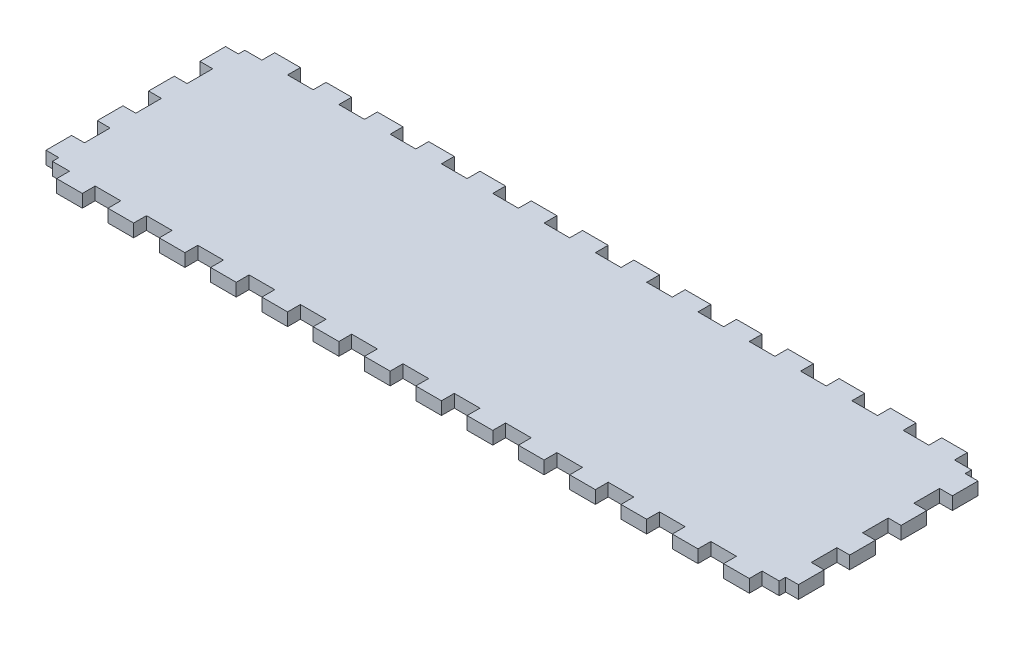
from build123d import *

# Parameters (mm, degrees)
SKETCH1_W                = 170
SKETCH1_H                = 45
BOSS_EXTRUDE1_DEPTH      = 3
SKETCH2_W                = 6
SKETCH2_H                = 3
BOSS_EXTRUDE2_DEPTH      = 3
LPATTERN1_COUNT          = 7
LPATTERN1_PITCH          = 12
LPATTERN1_COL_COUNT      = 8
LPATTERN1_COL_PITCH      = 12
SKETCH3_W                = 6
SKETCH3_H                = 3
BOSS_EXTRUDE3_DEPTH      = 3
LPATTERN2_COUNT          = 2
LPATTERN2_PITCH          = 12
LPATTERN2_COL_COUNT      = 3
LPATTERN2_COL_PITCH      = 12
MIRROR1_COPY_1_SKETCH_W  = 6
MIRROR1_COPY_1_SKETCH_H  = 3
MIRROR1_COPY_1_DEPTH     = 3
MIRROR1_COPY_2_SKETCH_W  = 6
MIRROR1_COPY_2_SKETCH_H  = 3
MIRROR1_COPY_2_DEPTH     = 3
MIRROR1_COPY_3_SKETCH_W  = 6
MIRROR1_COPY_3_SKETCH_H  = 3
MIRROR1_COPY_3_DEPTH     = 3
MIRROR1_COPY_4_SKETCH_W  = 6
MIRROR1_COPY_4_SKETCH_H  = 3
MIRROR1_COPY_4_DEPTH     = 3
MIRROR1_COPY_5_SKETCH_W  = 6
MIRROR1_COPY_5_SKETCH_H  = 3
MIRROR1_COPY_5_DEPTH     = 3
MIRROR1_COPY_6_SKETCH_W  = 6
MIRROR1_COPY_6_SKETCH_H  = 3
MIRROR1_COPY_6_DEPTH     = 3
MIRROR1_COPY_7_SKETCH_W  = 6
MIRROR1_COPY_7_SKETCH_H  = 3
MIRROR1_COPY_7_DEPTH     = 3
MIRROR1_COPY_8_SKETCH_W  = 6
MIRROR1_COPY_8_SKETCH_H  = 3
MIRROR1_COPY_8_DEPTH     = 3
MIRROR1_COPY_9_SKETCH_W  = 6
MIRROR1_COPY_9_SKETCH_H  = 3
MIRROR1_COPY_9_DEPTH     = 3
MIRROR1_COPY_10_SKETCH_W = 6
MIRROR1_COPY_10_SKETCH_H = 3
MIRROR1_COPY_10_DEPTH    = 3
MIRROR1_COPY_11_SKETCH_W = 6
MIRROR1_COPY_11_SKETCH_H = 3
MIRROR1_COPY_11_DEPTH    = 3
MIRROR1_COPY_12_SKETCH_W = 6
MIRROR1_COPY_12_SKETCH_H = 3
MIRROR1_COPY_12_DEPTH    = 3
MIRROR1_COPY_13_SKETCH_W = 6
MIRROR1_COPY_13_SKETCH_H = 3
MIRROR1_COPY_13_DEPTH    = 3
MIRROR2_COPY_1_SKETCH_W  = 6
MIRROR2_COPY_1_SKETCH_H  = 3
MIRROR2_COPY_1_DEPTH     = 3
MIRROR2_COPY_2_SKETCH_W  = 6
MIRROR2_COPY_2_SKETCH_H  = 3
MIRROR2_COPY_2_DEPTH     = 3
MIRROR2_COPY_3_SKETCH_W  = 6
MIRROR2_COPY_3_SKETCH_H  = 3
MIRROR2_COPY_3_DEPTH     = 3


with BuildPart() as part:
    # Sketch1 → Boss-Extrude1 (new body)
    with BuildSketch(Plane(origin=(0, 0, 0), x_dir=(1, 0, 0), z_dir=(0, 1, 0))):
        Rectangle(SKETCH1_W, SKETCH1_H)
    extrude(amount=BOSS_EXTRUDE1_DEPTH)

    # Sketch2 → Boss-Extrude2 (add)
    with BuildSketch(Plane.XY.offset(22.5)):
        with Locations((6, 1.5)):
            Rectangle(SKETCH2_W, SKETCH2_H)
    boss_extrude2 = extrude(amount=BOSS_EXTRUDE2_DEPTH)

    # LPattern1: Boss-Extrude2 ×7
    with Locations(*[(i * LPATTERN1_PITCH, 0, 0) for i in range(1, LPATTERN1_COUNT)]):
        add(boss_extrude2)

    # LPattern1 col: Boss-Extrude2 ×8
    with Locations(*[(-i * LPATTERN1_COL_PITCH, 0, 0) for i in range(1, LPATTERN1_COL_COUNT)]):
        add(boss_extrude2)

    # Sketch3 → Boss-Extrude3 (add)
    with BuildSketch(Plane(origin=(85, 0, 0), x_dir=(0, 0, -1), z_dir=(1, 0, 0))):
        with Locations((6, 1.5)):
            Rectangle(SKETCH3_W, SKETCH3_H)
    boss_extrude3 = extrude(amount=BOSS_EXTRUDE3_DEPTH)

    # LPattern2: Boss-Extrude3 ×2
    with Locations(*[(0, 0, -i * LPATTERN2_PITCH) for i in range(1, LPATTERN2_COUNT)]):
        add(boss_extrude3)

    # LPattern2 col: Boss-Extrude3 ×3
    with Locations(*[(0, 0, i * LPATTERN2_COL_PITCH) for i in range(1, LPATTERN2_COL_COUNT)]):
        add(boss_extrude3)

    # Mirror1: Boss-Extrude2 across plane
    add(boss_extrude2.mirror(Plane(origin=(0, 0, 0), x_dir=(1, 0, 0), z_dir=(0, 0, -1))))

    # Mirror1 copy 1 sketch → Mirror1 copy 1 (add)
    with BuildSketch(Plane(origin=(12, 0, -22.5), x_dir=(1, 0, 0), z_dir=(0, 0, -1))):
        with Locations((6, -1.5)):
            Rectangle(MIRROR1_COPY_1_SKETCH_W, MIRROR1_COPY_1_SKETCH_H)
    extrude(amount=MIRROR1_COPY_1_DEPTH)

    # Mirror1 copy 2 sketch → Mirror1 copy 2 (add)
    with BuildSketch(Plane(origin=(24, 0, -22.5), x_dir=(1, 0, 0), z_dir=(0, 0, -1))):
        with Locations((6, -1.5)):
            Rectangle(MIRROR1_COPY_2_SKETCH_W, MIRROR1_COPY_2_SKETCH_H)
    extrude(amount=MIRROR1_COPY_2_DEPTH)

    # Mirror1 copy 3 sketch → Mirror1 copy 3 (add)
    with BuildSketch(Plane(origin=(36, 0, -22.5), x_dir=(1, 0, 0), z_dir=(0, 0, -1))):
        with Locations((6, -1.5)):
            Rectangle(MIRROR1_COPY_3_SKETCH_W, MIRROR1_COPY_3_SKETCH_H)
    extrude(amount=MIRROR1_COPY_3_DEPTH)

    # Mirror1 copy 4 sketch → Mirror1 copy 4 (add)
    with BuildSketch(Plane(origin=(48, 0, -22.5), x_dir=(1, 0, 0), z_dir=(0, 0, -1))):
        with Locations((6, -1.5)):
            Rectangle(MIRROR1_COPY_4_SKETCH_W, MIRROR1_COPY_4_SKETCH_H)
    extrude(amount=MIRROR1_COPY_4_DEPTH)

    # Mirror1 copy 5 sketch → Mirror1 copy 5 (add)
    with BuildSketch(Plane(origin=(60, 0, -22.5), x_dir=(1, 0, 0), z_dir=(0, 0, -1))):
        with Locations((6, -1.5)):
            Rectangle(MIRROR1_COPY_5_SKETCH_W, MIRROR1_COPY_5_SKETCH_H)
    extrude(amount=MIRROR1_COPY_5_DEPTH)

    # Mirror1 copy 6 sketch → Mirror1 copy 6 (add)
    with BuildSketch(Plane(origin=(72, 0, -22.5), x_dir=(1, 0, 0), z_dir=(0, 0, -1))):
        with Locations((6, -1.5)):
            Rectangle(MIRROR1_COPY_6_SKETCH_W, MIRROR1_COPY_6_SKETCH_H)
    extrude(amount=MIRROR1_COPY_6_DEPTH)

    # Mirror1 copy 7 sketch → Mirror1 copy 7 (add)
    with BuildSketch(Plane(origin=(-12, 0, -22.5), x_dir=(1, 0, 0), z_dir=(0, 0, -1))):
        with Locations((6, -1.5)):
            Rectangle(MIRROR1_COPY_7_SKETCH_W, MIRROR1_COPY_7_SKETCH_H)
    extrude(amount=MIRROR1_COPY_7_DEPTH)

    # Mirror1 copy 8 sketch → Mirror1 copy 8 (add)
    with BuildSketch(Plane(origin=(-24, 0, -22.5), x_dir=(1, 0, 0), z_dir=(0, 0, -1))):
        with Locations((6, -1.5)):
            Rectangle(MIRROR1_COPY_8_SKETCH_W, MIRROR1_COPY_8_SKETCH_H)
    extrude(amount=MIRROR1_COPY_8_DEPTH)

    # Mirror1 copy 9 sketch → Mirror1 copy 9 (add)
    with BuildSketch(Plane(origin=(-36, 0, -22.5), x_dir=(1, 0, 0), z_dir=(0, 0, -1))):
        with Locations((6, -1.5)):
            Rectangle(MIRROR1_COPY_9_SKETCH_W, MIRROR1_COPY_9_SKETCH_H)
    extrude(amount=MIRROR1_COPY_9_DEPTH)

    # Mirror1 copy 10 sketch → Mirror1 copy 10 (add)
    with BuildSketch(Plane(origin=(-48, 0, -22.5), x_dir=(1, 0, 0), z_dir=(0, 0, -1))):
        with Locations((6, -1.5)):
            Rectangle(MIRROR1_COPY_10_SKETCH_W, MIRROR1_COPY_10_SKETCH_H)
    extrude(amount=MIRROR1_COPY_10_DEPTH)

    # Mirror1 copy 11 sketch → Mirror1 copy 11 (add)
    with BuildSketch(Plane(origin=(-60, 0, -22.5), x_dir=(1, 0, 0), z_dir=(0, 0, -1))):
        with Locations((6, -1.5)):
            Rectangle(MIRROR1_COPY_11_SKETCH_W, MIRROR1_COPY_11_SKETCH_H)
    extrude(amount=MIRROR1_COPY_11_DEPTH)

    # Mirror1 copy 12 sketch → Mirror1 copy 12 (add)
    with BuildSketch(Plane(origin=(-72, 0, -22.5), x_dir=(1, 0, 0), z_dir=(0, 0, -1))):
        with Locations((6, -1.5)):
            Rectangle(MIRROR1_COPY_12_SKETCH_W, MIRROR1_COPY_12_SKETCH_H)
    extrude(amount=MIRROR1_COPY_12_DEPTH)

    # Mirror1 copy 13 sketch → Mirror1 copy 13 (add)
    with BuildSketch(Plane(origin=(-84, 0, -22.5), x_dir=(1, 0, 0), z_dir=(0, 0, -1))):
        with Locations((6, -1.5)):
            Rectangle(MIRROR1_COPY_13_SKETCH_W, MIRROR1_COPY_13_SKETCH_H)
    extrude(amount=MIRROR1_COPY_13_DEPTH)

    # Mirror2: Boss-Extrude3 across plane
    add(boss_extrude3.mirror(Plane.ZY))

    # Mirror2 copy 1 sketch → Mirror2 copy 1 (add)
    with BuildSketch(Plane(origin=(-85, 0, -12), x_dir=(0, 0, -1), z_dir=(-1, 0, 0))):
        with Locations((6, -1.5)):
            Rectangle(MIRROR2_COPY_1_SKETCH_W, MIRROR2_COPY_1_SKETCH_H)
    extrude(amount=MIRROR2_COPY_1_DEPTH)

    # Mirror2 copy 2 sketch → Mirror2 copy 2 (add)
    with BuildSketch(Plane(origin=(-85, 0, 12), x_dir=(0, 0, -1), z_dir=(-1, 0, 0))):
        with Locations((6, -1.5)):
            Rectangle(MIRROR2_COPY_2_SKETCH_W, MIRROR2_COPY_2_SKETCH_H)
    extrude(amount=MIRROR2_COPY_2_DEPTH)

    # Mirror2 copy 3 sketch → Mirror2 copy 3 (add)
    with BuildSketch(Plane(origin=(-85, 0, 24), x_dir=(0, 0, -1), z_dir=(-1, 0, 0))):
        with Locations((6, -1.5)):
            Rectangle(MIRROR2_COPY_3_SKETCH_W, MIRROR2_COPY_3_SKETCH_H)
    extrude(amount=MIRROR2_COPY_3_DEPTH)


solid = part.part
